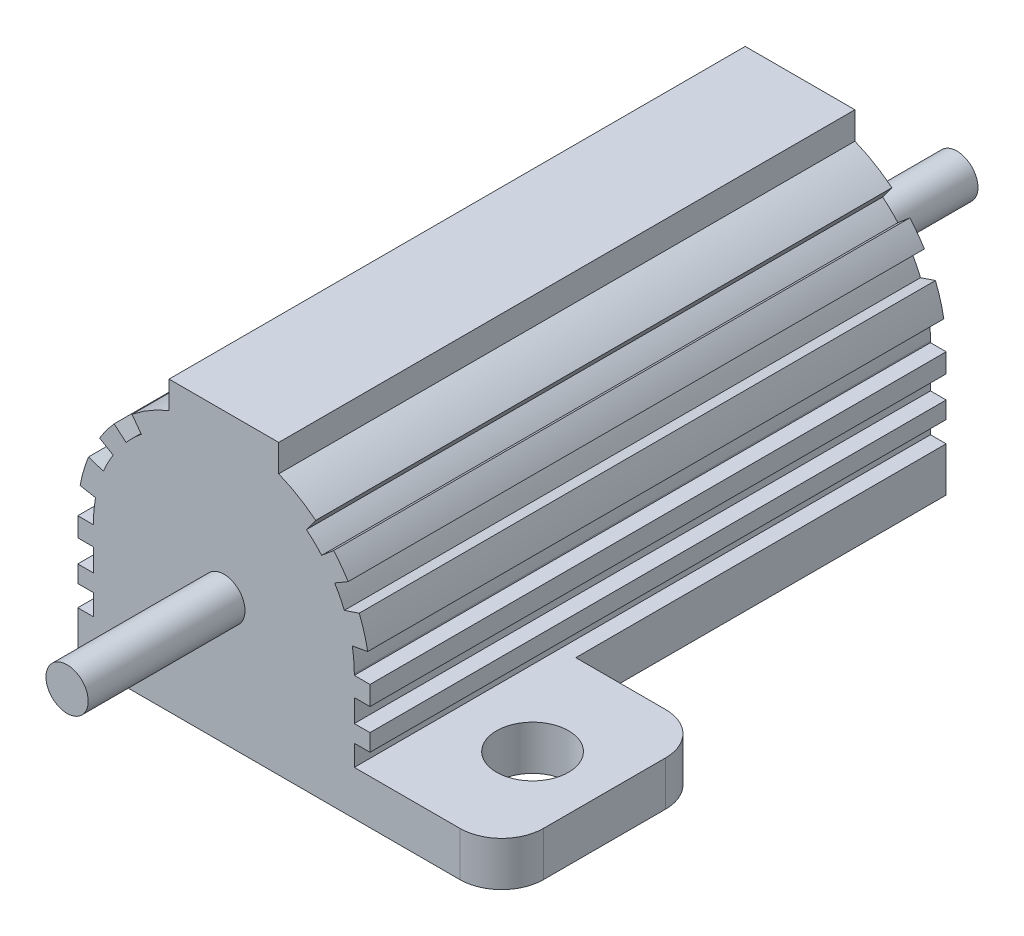
from build123d import *

# Parameters (mm, degrees)
EXTRUDE1_DEPTH     = 14
SKETCH4_W          = 6.4
SKETCH4_H          = 10
EXTRUDE8_DEPTH     = 2.159
FILLET1_R          = 2.032
CUT_EXTRUDE1_START = -28
SKETCH3_W          = 0.762
SKETCH3_H          = 1.095986398
SKETCH3_H_2        = 1.017694432
CUT_EXTRUDE1_DEPTH = 28
SKETCH5_R          = 1.75
CUT_EXTRUDE2_DEPTH = 3.159
SKETCH6_R          = 1.02616
EXTRUDE9_DEPTH     = 7.62


with BuildPart() as part:
    # Sketch2 → Extrude1 (new body, symmetric)
    with BuildSketch(Plane.XY):
        with BuildLine():
            Line((-7.1, 0), (7.1, 0))
            Line((7.1, 0), (7.1, 6.096))
            ThreePointArc((7.1, 6.096), (5.887891848, 10.063710875), (2.665428286, 12.676690849))
            Line((2.665428286, 12.676690849), (2.665428286, 14))
            Line((2.665428286, 14), (-2.665428286, 14))
            Line((-2.665428286, 14), (-2.665428286, 12.676690849))
            ThreePointArc((-2.665428286, 12.676690849), (-5.887891848, 10.063710875), (-7.1, 6.096))
            Line((-7.1, 6.096), (-7.1, 0))
        make_face()
    extrude(amount=EXTRUDE1_DEPTH, both=True)

    # Sketch4 → Extrude8 (add)
    with BuildSketch(Plane.XZ):
        with Locations((-10.3, -9)):
            Rectangle(SKETCH4_W, SKETCH4_H)
        with Locations((10.3, 9)):
            Rectangle(SKETCH4_W, SKETCH4_H)
    extrude(amount=-EXTRUDE8_DEPTH)

    # Fillet1
    fillet1_edges = [part.edges().sort_by_distance(p)[0] for p in [
        (-13.5, 1.0795, -14),
        (-13.5, 1.0795, -4),
        (13.5, 1.0795, 14),
        (13.5, 1.0795, 4),
    ]]
    fillet(fillet1_edges, radius=FILLET1_R)

    # Sketch3 → Cut-Extrude1 (cut)
    with BuildSketch(Plane.XY.offset(14).offset(CUT_EXTRUDE1_START)):
        with Locations((6.719, 4.552283628)):
            Rectangle(SKETCH3_W, SKETCH3_H)
        with BuildLine():
            Line((6.236968685, 7.223149334), (6.986821973, 7.358663344))
            ThreePointArc((6.986821973, 7.358663344), (7.071648889, 6.729862758), (7.1, 6.096))
            Line((7.1, 6.096), (7.1, 6.032119719))
            Line((7.1, 6.032119719), (6.338, 6.032119719))
            Line((6.338, 6.032119719), (6.338, 6.096))
            ThreePointArc((6.338, 6.096), (6.312691642, 6.661834107), (6.236968685, 7.223149334))
        make_face()
        with Locations((6.719, 2.667847216)):
            Rectangle(SKETCH3_W, SKETCH3_H_2)
        with BuildLine():
            Line((4.012570752, 11.002069706), (4.462775162, 11.618104477))
            ThreePointArc((4.462775162, 11.618104477), (4.915642764, 11.219129534), (5.332989208, 10.783134104))
            Line((5.332989208, 10.783134104), (4.752139233, 10.289735412))
            ThreePointArc((4.752139233, 10.289735412), (4.396804558, 10.660904564), (4.012570752, 11.002069706))
        make_face()
        with BuildLine():
            Line((5.381940738, 9.443380752), (6.039888527, 9.828257571))
            ThreePointArc((6.039888527, 9.828257571), (6.330841034, 9.310102022), (6.577443928, 8.769430636))
            Line((6.577443928, 8.769430636), (5.85354185, 8.526286364))
            ThreePointArc((5.85354185, 8.526286364), (5.636424644, 8.994441172), (5.381940738, 9.443380752))
        make_face()
    cut_extrude1 = extrude(amount=CUT_EXTRUDE1_DEPTH, mode=Mode.SUBTRACT)

    # Mirror2: Cut-Extrude1 across plane
    add(cut_extrude1.mirror(Plane(origin=(0, 0, 0), x_dir=(0, 0, 1), z_dir=(1, 0, 0))), mode=Mode.SUBTRACT)

    # Sketch5 → Cut-Extrude2 (cut, through all)
    with BuildSketch(Plane(origin=(0, 2.159, 0), x_dir=(-1, 0, 0), z_dir=(0, 1, 0))):
        with Locations((-10, 9)):
            Circle(SKETCH5_R)
        with Locations((10, -9)):
            Circle(SKETCH5_R)
    extrude(amount=-CUT_EXTRUDE2_DEPTH, mode=Mode.SUBTRACT)

    # Sketch6 → Extrude9 (add)
    with BuildSketch(Plane.XY.offset(14)):
        with Locations((0, 6.096)):
            Circle(SKETCH6_R)
    extrude9 = extrude(amount=EXTRUDE9_DEPTH)

    # Mirror3: Extrude9 across plane
    add(extrude9.mirror(Plane.XY))


solid = part.part
